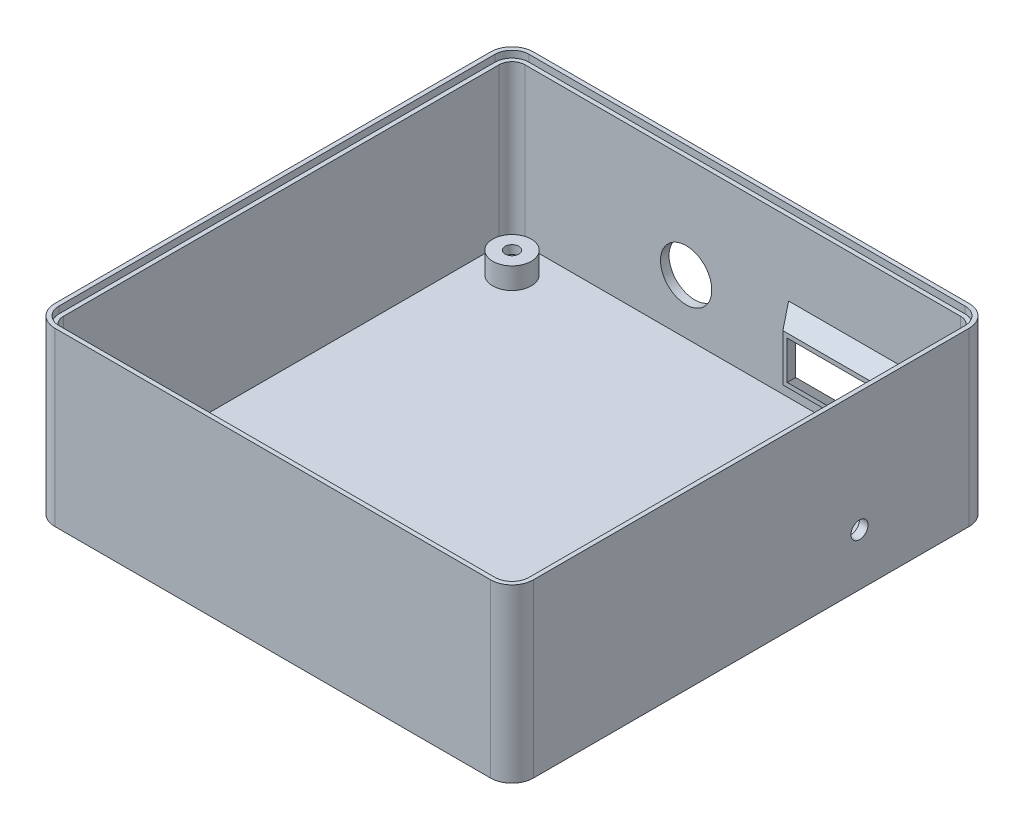
from build123d import *

# Parameters (mm, degrees)
BOSS_EXTRUDE1_DEPTH  = 40.2
CUT_EXTRUDE1_DEPTH   = 1.6
CUT_EXTRUDE2_DEPTH   = 36.6
SKETCH6_R            = 4.5
BOSS_EXTRUDE2_DEPTH  = 5
CUT_EXTRUDE4_START   = -8
SKETCH10_R           = 1.6
CUT_EXTRUDE4_DEPTH   = 42.2
SKETCH11_R           = 3.5
CUT_EXTRUDE6_DEPTH   = 5
LPATTERN1_COUNT      = 2
LPATTERN1_PITCH      = 93
LPATTERN1_COUNT_DIR2 = 2
LPATTERN1_PITCH_DIR2 = 93
SKETCH15_W           = 30.36
SKETCH15_H           = 19
SKETCH17_W           = 22.36
SKETCH17_H           = 11
SKETCH19_W           = 28.36
SKETCH19_H           = 17
SKETCH18_W           = 20.36
SKETCH18_H           = 9
CUT_EXTRUDE7_REACH   = 114
SKETCH21_R           = 2
CUT_EXTRUDE8_REACH   = 114
SKETCH22_R           = 6


with BuildPart() as part:
    # Sketch1 → Boss-Extrude1 (new body)
    with BuildSketch(Plane(origin=(0, 0, 0), x_dir=(1, 0, 0), z_dir=(0, 1, 0))):
        with BuildLine():
            Line((-51, -56), (51, -56))
            ThreePointArc((51, -56), (54.535533906, -54.535533906), (56, -51))
            Line((56, -51), (56, 51))
            ThreePointArc((56, 51), (54.535533906, 54.535533906), (51, 56))
            Line((51, 56), (-51, 56))
            ThreePointArc((-51, 56), (-54.535533906, 54.535533906), (-56, 51))
            Line((-56, 51), (-56, -51))
            ThreePointArc((-56, -51), (-54.535533906, -54.535533906), (-51, -56))
        make_face()
    extrude(amount=BOSS_EXTRUDE1_DEPTH)

    # Sketch3 → Cut-Extrude1 (cut)
    with BuildSketch(Plane(origin=(0, 40.2, 0), x_dir=(1, 0, 0), z_dir=(0, 1, 0))):
        with BuildLine():
            Line((-51, -55), (51, -55))
            ThreePointArc((51, -55), (53.828427125, -53.828427125), (55, -51))
            Line((55, -51), (55, 51))
            ThreePointArc((55, 51), (53.828427125, 53.828427125), (51, 55))
            Line((51, 55), (-51, 55))
            ThreePointArc((-51, 55), (-53.828427125, 53.828427125), (-55, 51))
            Line((-55, 51), (-55, -51))
            ThreePointArc((-55, -51), (-53.828427125, -53.828427125), (-51, -55))
        make_face()
    extrude(amount=-CUT_EXTRUDE1_DEPTH, mode=Mode.SUBTRACT)

    # Sketch4 → Cut-Extrude2 (cut)
    with BuildSketch(Plane(origin=(0, 38.6, 0), x_dir=(1, 0, 0), z_dir=(0, 1, 0))):
        with BuildLine():
            Line((-51, -54), (51, -54))
            ThreePointArc((51, -54), (53.121320344, -53.121320344), (54, -51))
            Line((54, -51), (54, 51))
            ThreePointArc((54, 51), (53.121320344, 53.121320344), (51, 54))
            Line((51, 54), (-51, 54))
            ThreePointArc((-51, 54), (-53.121320344, 53.121320344), (-54, 51))
            Line((-54, 51), (-54, -51))
            ThreePointArc((-54, -51), (-53.121320344, -53.121320344), (-51, -54))
        make_face()
    extrude(amount=-CUT_EXTRUDE2_DEPTH, mode=Mode.SUBTRACT)

    # Sketch6 → Boss-Extrude2 (add)
    with BuildSketch(Plane(origin=(0, 2, 0), x_dir=(1, 0, 0), z_dir=(0, 1, 0))):
        with Locations((-46.5, 46.5)):
            Circle(SKETCH6_R)
    boss_extrude2 = extrude(amount=BOSS_EXTRUDE2_DEPTH)

    # Sketch10 → Cut-Extrude4 (cut)
    with BuildSketch(Plane(origin=(0, 7, 0), x_dir=(1, 0, 0), z_dir=(0, 1, 0)).offset(CUT_EXTRUDE4_START)):
        with Locations((-46.5, 46.5)):
            Circle(SKETCH10_R)
    cut_extrude4 = extrude(amount=CUT_EXTRUDE4_DEPTH, mode=Mode.SUBTRACT)

    # Sketch11 → Cut-Extrude6 (cut)
    with BuildSketch(Plane.XZ):
        with Locations((-46.5, -46.5)):
            Circle(SKETCH11_R)
    cut_extrude6 = extrude(amount=-CUT_EXTRUDE6_DEPTH, mode=Mode.SUBTRACT)

    # LPattern1: Boss-Extrude2, Cut-Extrude4, Cut-Extrude6 2 × 2
    with Locations(*[(j * LPATTERN1_PITCH_DIR2, 0, i * LPATTERN1_PITCH) for i in range(LPATTERN1_COUNT) for j in range(LPATTERN1_COUNT_DIR2) if (i, j) != (0, 0)]):
        add(boss_extrude2)
        add(cut_extrude4, mode=Mode.SUBTRACT)
        add(cut_extrude6, mode=Mode.SUBTRACT)

    # Sketch15 → Loft1 section 0
    with BuildSketch(Plane(origin=(0, 0, -56), x_dir=(-1, 0, 0), z_dir=(0, 0, -1))):
        with Locations((-24.58, 13.4)):
            Rectangle(SKETCH15_W, SKETCH15_H)
    # Sketch17 → Loft1 section 1
    with BuildSketch(Plane.XY.offset(-50)):
        with Locations((24.58, 13.4)):
            Rectangle(SKETCH17_W, SKETCH17_H)
    loft()

    # Sketch19 → Cut-Loft2 section 0
    with BuildSketch(Plane(origin=(0, 0, -56), x_dir=(-1, 0, 0), z_dir=(0, 0, -1))):
        with Locations((-24.58, 13.4)):
            Rectangle(SKETCH19_W, SKETCH19_H)
    # Sketch18 → Cut-Loft2 section 1
    with BuildSketch(Plane.XY.offset(-50)):
        with Locations((24.58, 13.4)):
            Rectangle(SKETCH18_W, SKETCH18_H)
    loft(mode=Mode.SUBTRACT)

    # Sketch21 → Cut-Extrude7 (cut, up to next)
    with BuildSketch(Plane(origin=(56, 0.222876175, 12.489592586), x_dir=(0, 0, -1), z_dir=(1, 0, 0)), mode=Mode.PRIVATE) as cut_extrude7_sk1:
        with Locations((37.808139586, 11.956230245)):
            Circle(SKETCH21_R)
    cut_extrude7_tool1 = extrude(cut_extrude7_sk1.sketch, amount=-CUT_EXTRUDE7_REACH, mode=Mode.PRIVATE) & part.part
    add(cut_extrude7_tool1.solids().sort_by_distance((56, 12.179106, -25.318547))[0], mode=Mode.SUBTRACT)

    # Sketch22 → Cut-Extrude8 (cut, up to next)
    with BuildSketch(Plane(origin=(0, 0, -56), x_dir=(-1, 0, 0), z_dir=(0, 0, -1)), mode=Mode.PRIVATE) as cut_extrude8_sk1:
        with Locations((13.246177, 14.809453668)):
            Circle(SKETCH22_R)
    cut_extrude8_tool1 = extrude(cut_extrude8_sk1.sketch, amount=-CUT_EXTRUDE8_REACH, mode=Mode.PRIVATE) & part.part
    add(cut_extrude8_tool1.solids().sort_by_distance((-13.246177, 14.809454, -56))[0], mode=Mode.SUBTRACT)


solid = part.part
